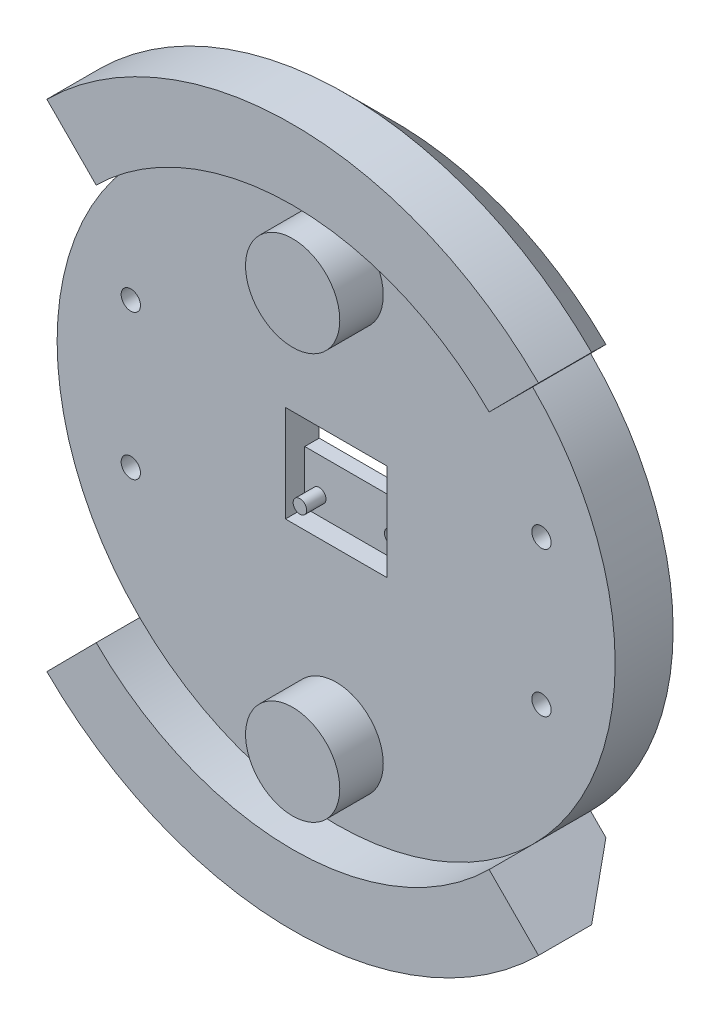
from build123d import *

# Parameters (mm, degrees)
SKETCH1_R               = 57.75
BOSS_EXTRUDE2_DEPTH     = 12
BOSS_EXTRUDE3_DEPTH     = 21
SKETCH2_W               = 101
SKETCH2_H               = 51
CUT_EXTRUDE1_DEPTH      = 5
SKETCH4_W               = 21
SKETCH4_H               = 20
CUT_EXTRUDE2_DEPTH      = 8
SKETCH5_W               = 21
SKETCH5_H               = 40.810106116
CUT_EXTRUDE3_DEPTH      = 35
CUT_EXTRUDE3_DEPTH_BACK = 3
SKETCH6_W               = 21
SKETCH6_H               = 10.991891623
BOSS_EXTRUDE4_DEPTH     = 3
SKETCH9_R               = 2
CUT_EXTRUDE6_DEPTH      = 31
SKETCH12_R              = 9.75
BOSS_EXTRUDE5_DEPTH     = 9
SKETCH7_R               = 1.4
BOSS_EXTRUDE6_DEPTH     = 7
SKETCH7_6_R             = 1.5
CUT_EXTRUDE10_DEPTH     = 10
CHAMFER1_SIZE           = 10


with BuildPart() as part:
    # Sketch1 → Boss-Extrude2 (new body)
    with BuildSketch(Plane.XY):
        with Locations((-3.428783881, -2.741891623)):
            Circle(SKETCH1_R)
    extrude(amount=BOSS_EXTRUDE2_DEPTH)

    # Sketch1_4 → Boss-Extrude3 (add)
    with BuildSketch(Plane.XY):
        with BuildLine():
            Line((-54.304676832, 48.558264482), (-44.094290011, 38.262731423))
            ThreePointArc((-44.094290011, 38.262731423), (-3.428783881, 55.008108377), (37.23672225, 38.262731423))
            Line((37.23672225, 38.262731423), (47.44710907, 48.558264482))
            ThreePointArc((47.44710907, 48.558264482), (-3.428783881, 69.508108377), (-54.304676832, 48.558264482))
        make_face()
        with BuildLine():
            ThreePointArc((37.23672225, -43.746514669), (-3.428783881, -60.491891623), (-44.094290011, -43.746514669))
            Line((-44.094290011, -43.746514669), (-54.304676832, -54.042047728))
            ThreePointArc((-54.304676832, -54.042047728), (-3.428783881, -74.991891623), (47.44710907, -54.042047728))
            Line((47.44710907, -54.042047728), (37.23672225, -43.746514669))
        make_face()
    extrude(amount=BOSS_EXTRUDE3_DEPTH)

    # Sketch2 → Cut-Extrude1 (cut)
    with BuildSketch(Plane(origin=(0, 0, 0), x_dir=(-1, 0, 0), z_dir=(0, 0, -1))):
        with Locations((3.428783881, -2.741891623)):
            Rectangle(SKETCH2_W, SKETCH2_H)
    extrude(amount=-CUT_EXTRUDE1_DEPTH, mode=Mode.SUBTRACT)

    # Sketch4 → Cut-Extrude2 (cut)
    with BuildSketch(Plane(origin=(0, 0, 5), x_dir=(-1, 0, 0), z_dir=(0, 0, -1))):
        with Locations((3.428783881, -0.991891623)):
            Rectangle(SKETCH4_W, SKETCH4_H)
    extrude(amount=-CUT_EXTRUDE2_DEPTH, mode=Mode.SUBTRACT)

    # Sketch5 → Cut-Extrude3 (cut, two sides)
    with BuildSketch(Plane(origin=(0, 0, 5), x_dir=(-1, 0, 0), z_dir=(0, 0, -1))) as cut_extrude3_sk:
        with Locations((3.428783881, 9.413161435)):
            Rectangle(SKETCH5_W, SKETCH5_H)
    extrude(amount=CUT_EXTRUDE3_DEPTH, mode=Mode.SUBTRACT)
    extrude(cut_extrude3_sk.sketch, amount=-CUT_EXTRUDE3_DEPTH_BACK, mode=Mode.SUBTRACT)

    # Sketch6 → Boss-Extrude4 (add)
    with BuildSketch(Plane(origin=(0, 0, 5), x_dir=(-1, 0, 0), z_dir=(0, 0, -1))):
        with Locations((3.428783881, -5.495945812)):
            Rectangle(SKETCH6_W, SKETCH6_H)
    extrude(amount=-BOSS_EXTRUDE4_DEPTH)

    # Sketch9 → Cut-Extrude6 (cut)
    with BuildSketch(Plane.XY.offset(12)):
        with Locations((-45.928783881, -17.741891623)):
            Circle(SKETCH9_R)
        with Locations((-45.928783881, 12.258108377)):
            Circle(SKETCH9_R)
        with Locations((39.071216119, 12.258108377)):
            Circle(SKETCH9_R)
        with Locations((39.071216119, -17.741891623)):
            Circle(SKETCH9_R)
    extrude(amount=-CUT_EXTRUDE6_DEPTH, mode=Mode.SUBTRACT)

    # Sketch12 → Boss-Extrude5 (add)
    with BuildSketch(Plane.XY.offset(12)):
        with Locations((-3.428783881, -44.741891623)):
            Circle(SKETCH12_R)
        with Locations((-3.428783881, 39.258108377)):
            Circle(SKETCH12_R)
    extrude(amount=BOSS_EXTRUDE5_DEPTH)

    # Sketch7 → Boss-Extrude6 (add)
    with BuildSketch(Plane(origin=(0, 0, 5), x_dir=(-1, 0, 0), z_dir=(0, 0, -1))):
        with Locations((10.928783881, -7.241891623)):
            Circle(SKETCH7_R)
    extrude(amount=-BOSS_EXTRUDE6_DEPTH)

    # Sketch7_6 → Cut-Extrude10 (cut)
    with BuildSketch(Plane(origin=(0, 0, 5), x_dir=(-1, 0, 0), z_dir=(0, 0, -1))):
        with Locations((-4.071216119, -7.241891623)):
            Circle(SKETCH7_6_R)
    extrude(amount=-CUT_EXTRUDE10_DEPTH, mode=Mode.SUBTRACT)

    # Chamfer1
    chamfer1_edges = [part.edges().sort_by_distance(p)[0] for p in [
        (-3.428783881, -74.991891623, 0),
        (-3.428783881, 69.508108377, 0),
    ]]
    chamfer(chamfer1_edges, length=CHAMFER1_SIZE)


solid = part.part
